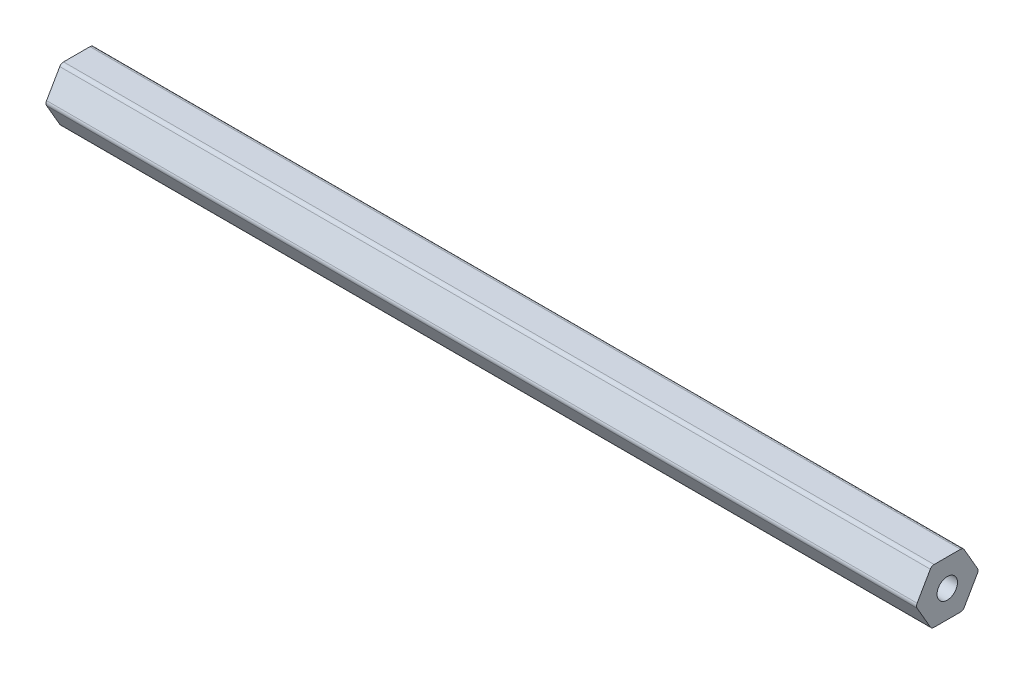
from build123d import *

# Parameters (mm, degrees)
SKETCH1_R           = 2.38125
BOSS_EXTRUDE1_DEPTH = 203.2


with BuildPart() as part:
    # Sketch1 → Boss-Extrude1 (new body)
    with BuildSketch(Plane(origin=(0, 0, 0), x_dir=(0, 0, -1), z_dir=(1, 0, 0))):
        with BuildLine():
            Line((7.039054482, 0.508), (3.959468146, 5.842))
            ThreePointArc((3.959468146, 5.842), (3.587586336, 6.21388181), (3.079586336, 6.35))
            Line((3.079586336, 6.35), (-3.079586336, 6.35))
            ThreePointArc((-3.079586336, 6.35), (-3.587586336, 6.21388181), (-3.959468146, 5.842))
            Line((-3.959468146, 5.842), (-7.039054482, 0.508))
            ThreePointArc((-7.039054482, 0.508), (-7.175172672, 0), (-7.039054482, -0.508))
            Line((-7.039054482, -0.508), (-3.959468146, -5.842))
            ThreePointArc((-3.959468146, -5.842), (-3.587586336, -6.21388181), (-3.079586336, -6.35))
            Line((-3.079586336, -6.35), (3.079586336, -6.35))
            ThreePointArc((3.079586336, -6.35), (3.587586336, -6.21388181), (3.959468146, -5.842))
            Line((3.959468146, -5.842), (7.039054482, -0.508))
            ThreePointArc((7.039054482, -0.508), (7.175172672, 0), (7.039054482, 0.508))
        make_face()
        Circle(SKETCH1_R, mode=Mode.SUBTRACT)
    extrude(amount=BOSS_EXTRUDE1_DEPTH)


solid = part.part
